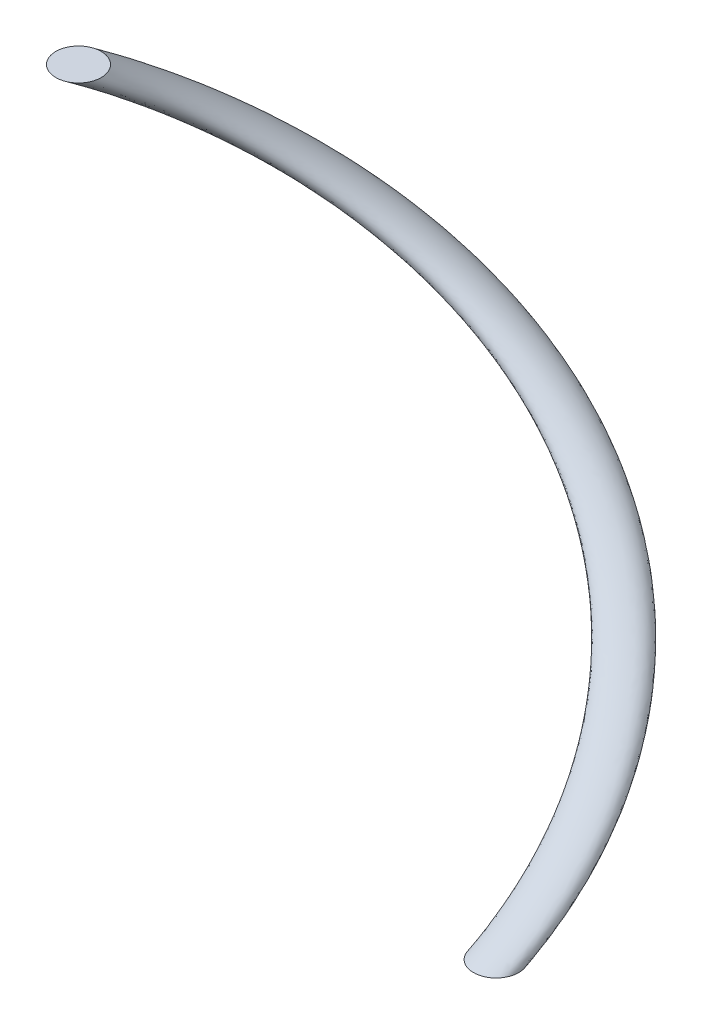
from build123d import *

# Parameters (mm, degrees)
SWEEP1_PITCH       = 90
SWEEP1_HEIGHT      = 43.2
SWEEP1_RADIUS      = 15
SWEEP1_START_ANGLE = 90
SKETCH1_R          = 2


with BuildPart() as part:
    # Sweep1: sweep along a helix
    with BuildLine() as sweep1_path:
        add(Helix(SWEEP1_PITCH, SWEEP1_HEIGHT, SWEEP1_RADIUS, center=(0, 0, 0), direction=(0, 1, 0), mode=Mode.PRIVATE).rotate(Axis((0, 0, 0), (0, 1, 0)), SWEEP1_START_ANGLE))
    # Sketch1 → Sweep1 (sweep)
    with BuildSketch(Plane(origin=(0, 0, 0), x_dir=(1, 0, 0), z_dir=(0, 1, 0))):
        with Locations((22, -2)):
            Circle(SKETCH1_R)
    sweep(path=sweep1_path.line, is_frenet=True)


solid = part.part
